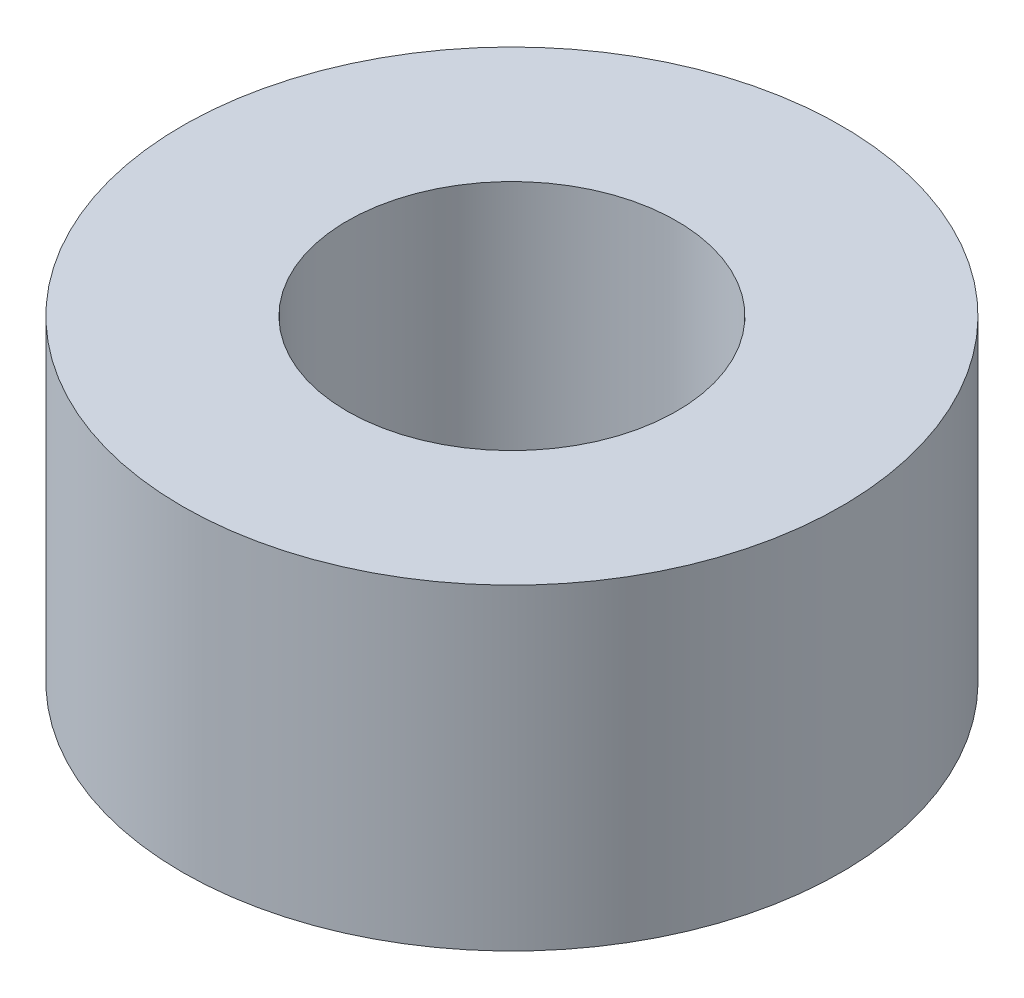
from build123d import *

# Parameters (mm, degrees)
SKETCH1_R           = 3.302
SKETCH1_R_2         = 1.651
BOSS_EXTRUDE1_DEPTH = 3.175


with BuildPart() as part:
    # Sketch1 → Boss-Extrude1 (new body)
    with BuildSketch(Plane(origin=(0, 0, 0), x_dir=(1, 0, 0), z_dir=(0, 1, 0))):
        Circle(SKETCH1_R)
        Circle(SKETCH1_R_2, mode=Mode.SUBTRACT)
    extrude(amount=BOSS_EXTRUDE1_DEPTH)


solid = part.part
